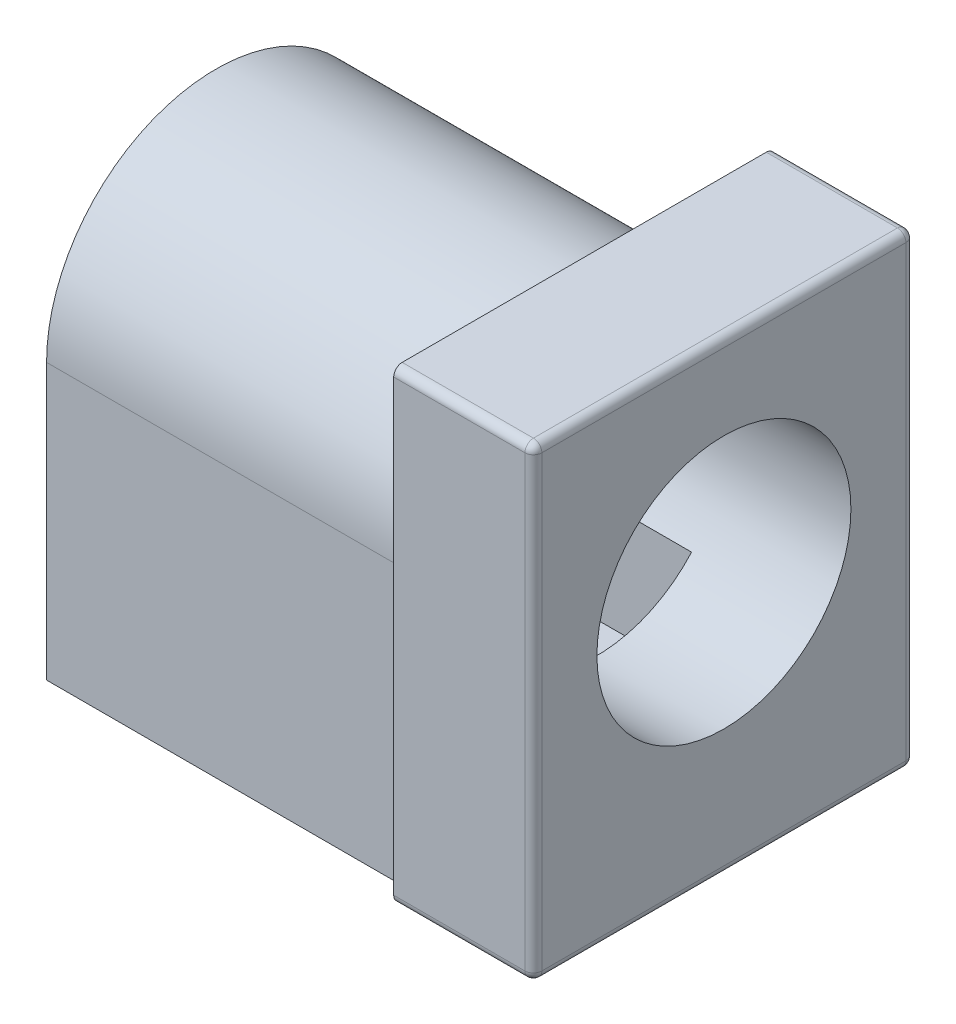
from build123d import *

# Parameters (mm, degrees)
SKETCH1_W               = 9
SKETCH1_H               = 11
BOSS_EXTRUDE1_DEPTH     = 12
CUT_EXTRUDE1_DEPTH      = 1
CUT_EXTRUDE1_DEPTH_BACK = 8.7
SKETCH3_R               = 3
CUT_EXTRUDE2_DEPTH      = 13
CUT_EXTRUDE3_REACH      = 13
SKETCH4_W               = 0.5
SKETCH4_H               = 3
FILLET1_R               = 0.2
CUT_EXTRUDE4_REACH      = 10.5
SKETCH5_W               = 3
SKETCH5_H               = 0.5
SKETCH6_W               = 4.472135954
SKETCH6_H               = 2.5
CUT_EXTRUDE5_DEPTH      = 9


with BuildPart() as part:
    # Sketch1 → Boss-Extrude1 (new body)
    with BuildSketch(Plane(origin=(0, 0, 0), x_dir=(0, 0, -1), z_dir=(1, 0, 0))):
        with Locations((4.5, 5.5)):
            Rectangle(SKETCH1_W, SKETCH1_H)
    extrude(amount=BOSS_EXTRUDE1_DEPTH)

    # Sketch2 → Cut-Extrude1 (cut, two sides)
    with BuildSketch(Plane.ZY) as cut_extrude1_sk:
        with BuildLine():
            Line((-8.5, 0), (-8.5, 6.5))
            ThreePointArc((-8.5, 6.5), (-4.5, 10.5), (-0.5, 6.5))
            Line((-0.5, 6.5), (-0.5, 0))
            Line((-0.5, 0), (0, 0))
            Line((0, 0), (0, 11))
            Line((0, 11), (-9, 11))
            Line((-9, 11), (-9, 0))
            Line((-9, 0), (-8.5, 0))
        make_face()
    extrude(amount=CUT_EXTRUDE1_DEPTH, mode=Mode.SUBTRACT)
    extrude(cut_extrude1_sk.sketch, amount=-CUT_EXTRUDE1_DEPTH_BACK, mode=Mode.SUBTRACT)

    # Sketch3 → Cut-Extrude2 (cut, through all)
    with BuildSketch(Plane(origin=(12, 0, 0), x_dir=(0, 0, -1), z_dir=(1, 0, 0))):
        with Locations((4.5, 6)):
            Circle(SKETCH3_R)
    extrude(amount=-CUT_EXTRUDE2_DEPTH, mode=Mode.SUBTRACT)

    # Sketch4 → Cut-Extrude3 (cut, up to next)
    with BuildSketch(Plane(origin=(0, 0, 0), x_dir=(-1, 0, 0), z_dir=(0, -1, 0)), mode=Mode.PRIVATE) as cut_extrude3_sk1:
        with Locations((-5, 4.5)):
            Rectangle(SKETCH4_W, SKETCH4_H)
    cut_extrude3_tool1 = extrude(cut_extrude3_sk1.sketch, amount=-CUT_EXTRUDE3_REACH, mode=Mode.PRIVATE) & part.part
    add(cut_extrude3_tool1.solids().sort_by_distance((5, 0, -4.5))[0], mode=Mode.SUBTRACT)

    # Fillet1
    fillet1_edges = [part.edges().sort_by_distance(p)[0] for p in [
        (12, 5.5, -9),
        (12, 11, -4.5),
        (12, 5.5, 0),
        (12, 0, -4.5),
        (10.35, 11, 0),
        (10.35, 11, -9),
        (10.35, 0, -9),
        (10.35, 0, 0),
    ]]
    fillet(fillet1_edges, radius=FILLET1_R)

    # Sketch5 → Cut-Extrude4 (cut, up to next)
    with BuildSketch(Plane(origin=(0, 0, -8.5), x_dir=(-1, 0, 0), z_dir=(0, 0, -1)), mode=Mode.PRIVATE) as cut_extrude4_sk1:
        with Locations((-1.5, 3.75)):
            Rectangle(SKETCH5_W, SKETCH5_H)
    cut_extrude4_tool1 = extrude(cut_extrude4_sk1.sketch, amount=-CUT_EXTRUDE4_REACH, mode=Mode.PRIVATE) & part.part
    add(cut_extrude4_tool1.solids().sort_by_distance((1.5, 3.75, -8.5))[0], mode=Mode.SUBTRACT)

    # Sketch6 → Cut-Extrude5 (cut)
    with BuildSketch(Plane.ZY):
        with Locations((-4.5, 2.75)):
            Rectangle(SKETCH6_W, SKETCH6_H)
    extrude(amount=-CUT_EXTRUDE5_DEPTH, mode=Mode.SUBTRACT)


solid = part.part
